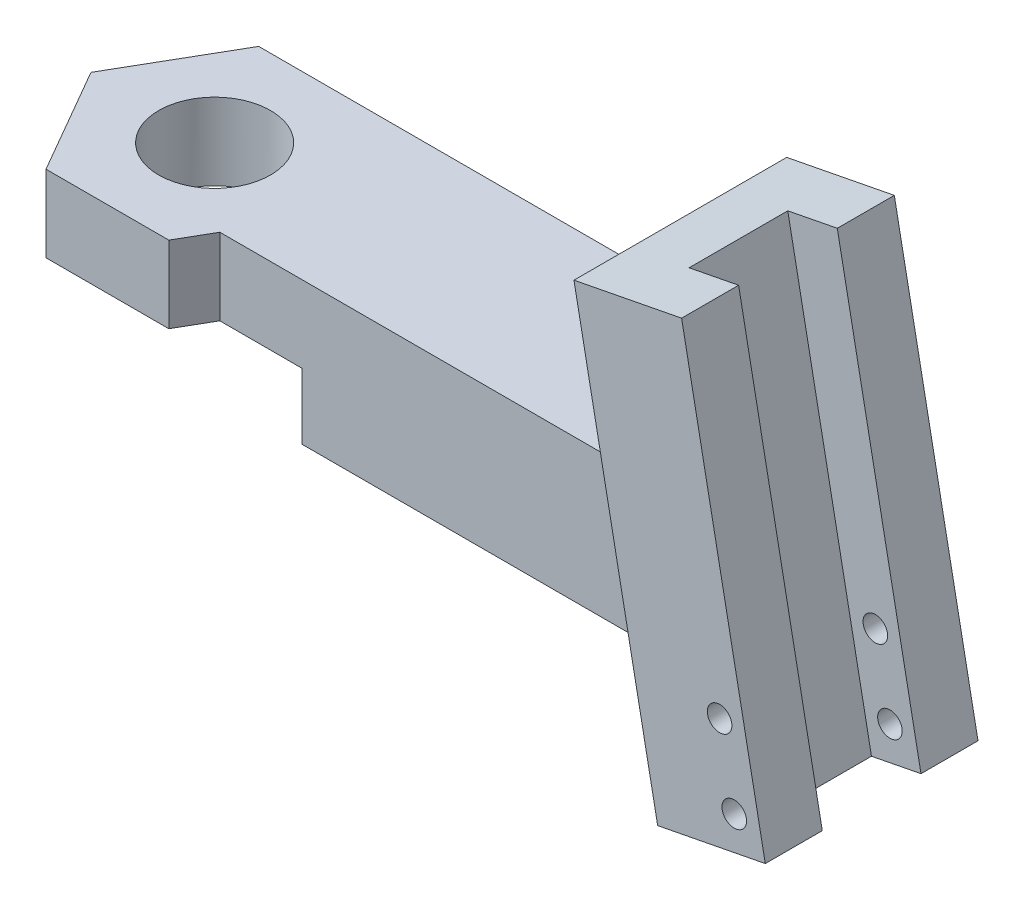
from build123d import *

# Parameters (mm, degrees)
SKETCH1_W                       = 25
SKETCH1_H                       = 6.75
BOSS_EXTRUDE1_DEPTH             = 6.5
BOSS_EXTRUDE4_DEPTH             = 6.5
BOSS_EXTRUDE3_REACH             = 6.85
BOSS_EXTRUDE3_DIRECTION_2_REACH = 6.85
SKETCH4_W                       = 2.3
SKETCH4_H                       = 4.5
CUT_EXTRUDE1_DEPTH              = 23
SKETCH6_R                       = 2.55
CUT_EXTRUDE2_DEPTH              = 10
BOSS_EXTRUDE5_DEPTH             = 1.475
CUT_EXTRUDE3_DEPTH              = 3
SKETCH9_R                       = 0.56
CUT_EXTRUDE4_DEPTH              = 9.7


with BuildPart() as part:
    # Sketch1 → Boss-Extrude1 (new body)
    with BuildSketch(Plane(origin=(0, 0, 0), x_dir=(1, 0, 0), z_dir=(0, 1, 0))):
        with Locations((12.5, -3.375)):
            Rectangle(SKETCH1_W, SKETCH1_H)
    extrude(amount=BOSS_EXTRUDE1_DEPTH)

    # Sketch5 → Boss-Extrude4 (add)
    with BuildSketch(Plane(origin=(0, 6.5, 0), x_dir=(1, 0, 0), z_dir=(0, 1, 0))):
        Polygon((-5.600297611, -3.375), (-2.800148806, -8.225), (2.800148806, -8.225), (5.600297611, -3.375), (2.800148806, 1.475), (-2.800148806, 1.475), align=None)
    extrude(amount=-BOSS_EXTRUDE4_DEPTH)

    # Boss-Extrude3: up to this face of the body (flat: up to its plane)
    boss_extrude3_end = Plane(part.part.faces().sort_by_distance((0, 3.25, -1.475))[0])
    # Sketch3 → Boss-Extrude3 (add, up to the picked face)
    with BuildSketch(Plane.XY.offset(3.375), mode=Mode.PRIVATE) as boss_extrude3_sk1:
        Polygon((21.275684175, 14.155521181), (26.183820092, 15.109566157), (30, -4.522977512), (25.091864083, -5.477022488), align=None)
    boss_extrude3_tool1 = split(extrude(boss_extrude3_sk1.sketch, amount=-BOSS_EXTRUDE3_REACH, mode=Mode.PRIVATE), bisect_by=boss_extrude3_end, keep=Keep.BOTH, mode=Mode.PRIVATE)
    add(boss_extrude3_tool1.solids().sort_by_distance((25.637842, 4.816272, 3.375))[0])

    # Boss-Extrude3 direction 2: up to this face of the body (flat: up to its plane)
    boss_extrude3_direction_2_end = Plane(part.part.faces().sort_by_distance((0, 3.25, 8.225))[0])
    # Sketch3 → Boss-Extrude3 direction 2 (add, up to the picked face)
    with BuildSketch(Plane.XY.offset(3.375), mode=Mode.PRIVATE) as boss_extrude3_direction_2_sk1:
        Polygon((21.275684175, 14.155521181), (26.183820092, 15.109566157), (30, -4.522977512), (25.091864083, -5.477022488), align=None)
    boss_extrude3_direction_2_tool1 = split(extrude(boss_extrude3_direction_2_sk1.sketch, amount=BOSS_EXTRUDE3_DIRECTION_2_REACH, mode=Mode.PRIVATE), bisect_by=boss_extrude3_direction_2_end, keep=Keep.BOTH, mode=Mode.PRIVATE)
    add(boss_extrude3_direction_2_tool1.solids().sort_by_distance((25.637842, 4.816272, 3.375))[0])

    # Sketch4 → Cut-Extrude1 (cut)
    with BuildSketch(Plane(origin=(-1.876769127, 9.65514015, 0), x_dir=(0.981627183, 0.190808995, 0), z_dir=(-0.190808995, 0.981627183, 0))):
        with Locations((27.435790708, -3.375)):
            Rectangle(SKETCH4_W, SKETCH4_H)
    extrude(amount=-CUT_EXTRUDE1_DEPTH, mode=Mode.SUBTRACT)

    # Sketch6 → Cut-Extrude2 (cut)
    with BuildSketch(Plane(origin=(0, 6.5, 0), x_dir=(1, 0, 0), z_dir=(0, 1, 0))):
        with Locations((0, -3.335615973)):
            Circle(SKETCH6_R)
    extrude(amount=-CUT_EXTRUDE2_DEPTH, mode=Mode.SUBTRACT)

    # Sketch7 → Boss-Extrude5 (add)
    with BuildSketch(Plane(origin=(0, 0, -1.475), x_dir=(-1, 0, 0), z_dir=(0, 0, -1))):
        Polygon((-2.800148806, 0), (-24.027238758, 0), (-25.091864083, -5.477022488), (-30, -4.522977512), (-26.183820092, 15.109566157), (-21.275684175, 14.155521181), (-22.763766749, 6.5), (-2.800148806, 6.5), align=None)
    extrude(amount=-BOSS_EXTRUDE5_DEPTH)

    # Sketch8 → Cut-Extrude3 (cut)
    with BuildSketch(Plane(origin=(0, 0, 0), x_dir=(-1, 0, 0), z_dir=(0, -1, 0))):
        Polygon((-4.67653718, -11.475), (4.67653718, -11.475), (9.353074361, -3.375), (4.67653718, 4.725), (-4.67653718, 4.725), (-9.353074361, -3.375), align=None)
    extrude(amount=-CUT_EXTRUDE3_DEPTH, mode=Mode.SUBTRACT)

    # Sketch9 → Cut-Extrude4 (cut)
    with BuildSketch(Plane(origin=(0, 0, -1.475), x_dir=(-1, 0, 0), z_dir=(0, 0, -1))):
        with Locations((-28.584915246, -3.269967081)):
            Circle(SKETCH9_R)
        with Locations((-27.917083762, 0.165728061)):
            Circle(SKETCH9_R)
    extrude(amount=-CUT_EXTRUDE4_DEPTH, mode=Mode.SUBTRACT)


solid = part.part
